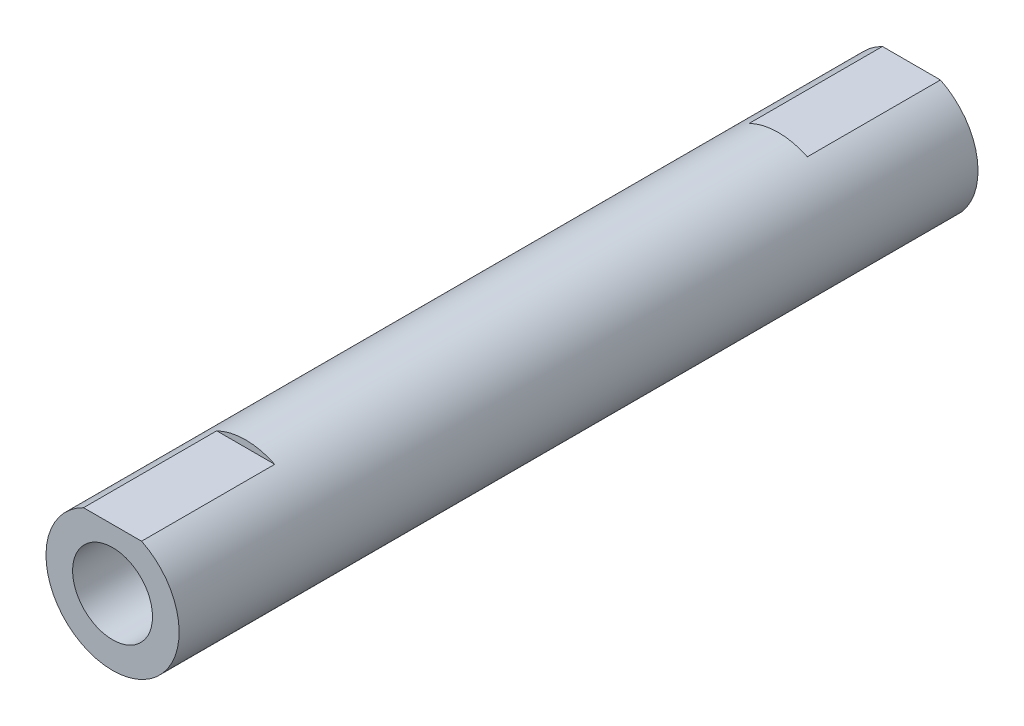
from build123d import *

# Parameters (mm, degrees)
SKETCH1_R           = 5
SKETCH1_R_2         = 3
BOSS_EXTRUDE2_DEPTH = 30
CUT_EXTRUDE1_DEPTH  = 10


with BuildPart() as part:
    # Sketch1 → Boss-Extrude2 (new body, symmetric)
    with BuildSketch(Plane.XY):
        Circle(SKETCH1_R)
        Circle(SKETCH1_R_2, mode=Mode.SUBTRACT)
    extrude(amount=BOSS_EXTRUDE2_DEPTH, both=True)

    # Sketch2 → Cut-Extrude1 (cut)
    with BuildSketch(Plane.XY.offset(30)):
        with BuildLine():
            Line((2.179449472, 4.5), (-2.179449472, 4.5))
            ThreePointArc((-2.179449472, 4.5), (0, 5), (2.179449472, 4.5))
        make_face()
    cut_extrude1 = extrude(amount=-CUT_EXTRUDE1_DEPTH, mode=Mode.SUBTRACT)

    # Mirror1: Cut-Extrude1 across plane
    add(cut_extrude1.mirror(Plane.XY), mode=Mode.SUBTRACT)


solid = part.part
